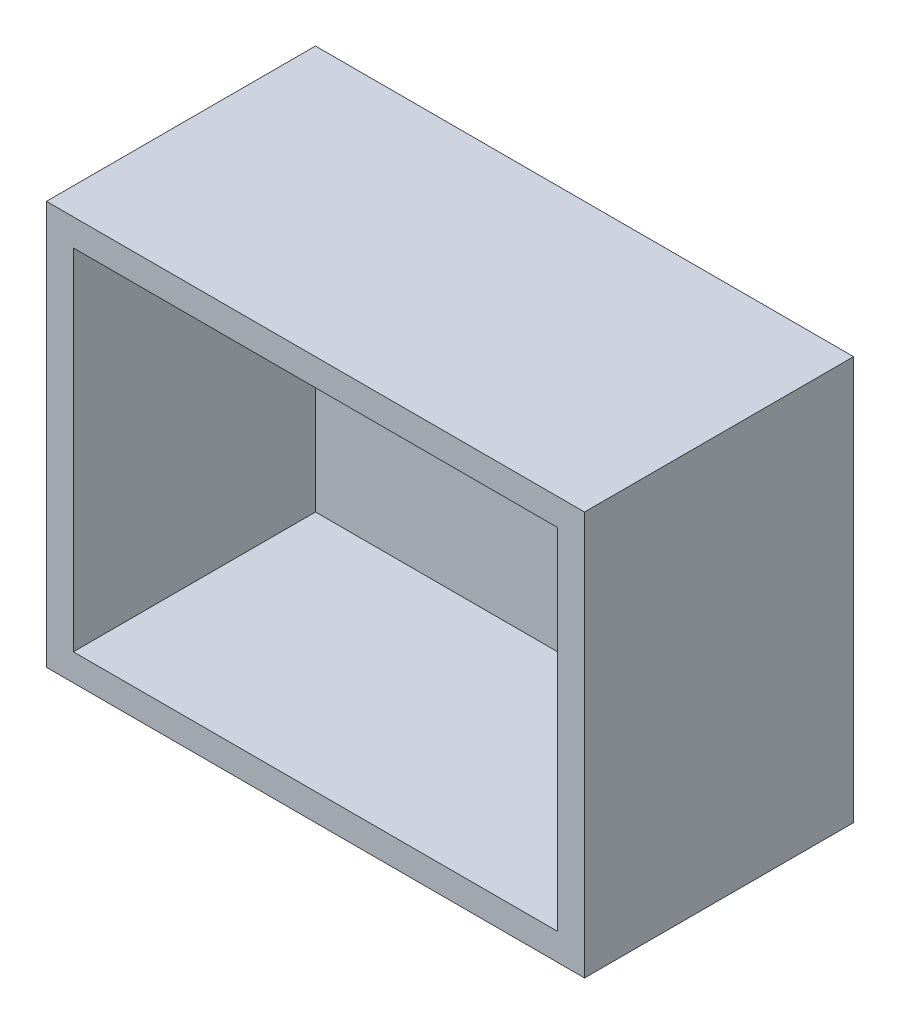
from build123d import *

# Parameters (mm, degrees)
SKETCH_1_W          = 40
SKETCH_1_H          = 30
EXTRUDE_1_DEPTH     = 20
SKETCH_2_W          = 36
SKETCH_2_H          = 26
CUT_EXTRUDE_2_DEPTH = 18


with BuildPart() as part:
    # 草图1 → 凸台-拉伸1 (new body)
    with BuildSketch(Plane.XY):
        with Locations((5.374514335, 12.518280569)):
            Rectangle(SKETCH_1_W, SKETCH_1_H)
    extrude(amount=EXTRUDE_1_DEPTH)

    # 草图2 → 切除-拉伸2 (cut)
    with BuildSketch(Plane.XY.offset(20)):
        with Locations((5.374514335, 12.518280569)):
            Rectangle(SKETCH_2_W, SKETCH_2_H)
    extrude(amount=-CUT_EXTRUDE_2_DEPTH, mode=Mode.SUBTRACT)


solid = part.part
